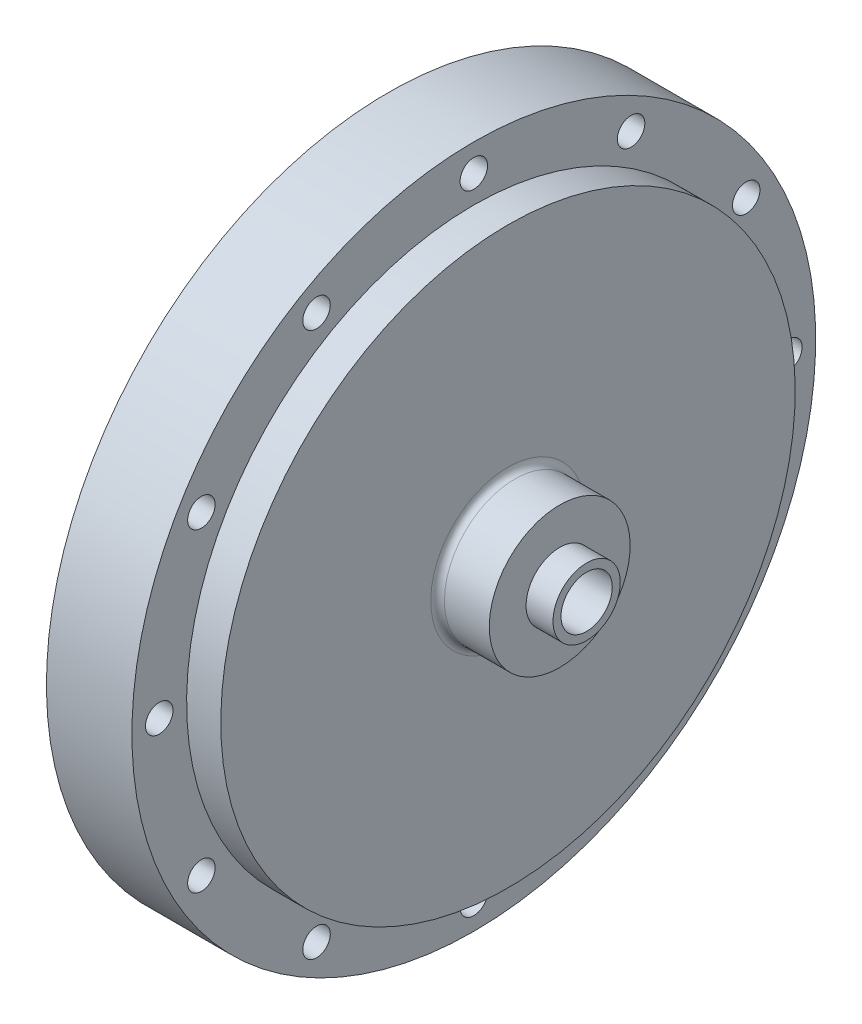
from build123d import *

# Parameters (mm, degrees)
SKETCH3_R                 = 4.7625
OXIDIZER_INLET_HOLE_DEPTH = 37.83
FLANGE_HOLES_D            = 5.1054
FLANGE_HOLES_DEPTH        = 22.225
DOWEL_HOLES_D             = 4.7625
DOWEL_HOLES_DEPTH         = 6.35
DOWEL_HOLES_TIP           = 1.430799349
SKETCH12_R                = 28.575
CUT_EXTRUDE2_DEPTH        = 9.525
SKETCH16_R                = 28.575
SKETCH17_R                = 4.7625
CIRPATTERN1_COUNT         = 8
FILLET1_R                 = 1.27
SKETCH25_OUTSIDE_W        = 165.668
SKETCH25_OUTSIDE_H        = 165.668
SKETCH25_OUTSIDE_R        = 53.34
CUT_EXTRUDE3_DEPTH        = 6.35


with BuildPart() as part:
    # Sketch2 → Main Structure (revolve)
    with BuildSketch(Plane.XY):
        Polygon((41.355, 13.081), (41.355, 6.2484), (46.355, 6.2484), (46.355, 0), (9.525, 0), (9.525, 63.5), (31.75, 63.5), (31.75, 13.081), align=None)
    revolve(axis=Axis((9.525, 0, 0), (1, 0, 0)))

    # Sketch3 → Oxidizer Inlet Hole (cut, through all)
    with BuildSketch(Plane(origin=(46.355, 0, 0), x_dir=(0, 0, -1), z_dir=(1, 0, 0))):
        Circle(SKETCH3_R)
    extrude(amount=-OXIDIZER_INLET_HOLE_DEPTH, mode=Mode.SUBTRACT)

    # Flange Holes
    with Locations(Plane(origin=(31.75, 0, 0), x_dir=(0, 0, 1), z_dir=(1, 0, 0))):
        with Locations((0, 58.42), (-29.21, 50.593204089), (-50.593204089, 29.21), (-58.42, 0), (-50.593204089, -29.21), (-29.21, -50.593204089), (0, -58.42), (29.21, -50.593204089), (50.593204089, -29.21), (58.42, 0), (50.593204089, 29.21), (29.21, 50.593204089)):
            Hole(FLANGE_HOLES_D / 2, depth=FLANGE_HOLES_DEPTH)

    # Dowel Holes
    with Locations(Plane.ZY.offset(-9.525)):
        with Locations((56.429386772, -15.120208615), (-56.429386772, 15.120208615)):
            Hole(DOWEL_HOLES_D / 2, depth=DOWEL_HOLES_DEPTH)
            with Locations((0, 0, -(DOWEL_HOLES_DEPTH + DOWEL_HOLES_TIP / 2))):  # 118° drill point
                Cone(0, DOWEL_HOLES_D / 2, DOWEL_HOLES_TIP, mode=Mode.SUBTRACT)

    # Sketch12 → Cut-Extrude2 (cut)
    with BuildSketch(Plane.ZY.offset(-9.525)):
        Circle(SKETCH12_R)
    extrude(amount=-CUT_EXTRUDE2_DEPTH, mode=Mode.SUBTRACT)

    # Sketch16 → Internal Flow Path Loft Cut section 0
    with BuildSketch(Plane.ZY.offset(-19.05)):
        Circle(SKETCH16_R)
    # Sketch17 → Internal Flow Path Loft Cut section 1
    with BuildSketch(Plane.ZY.offset(-30.48)):
        Circle(SKETCH17_R)
    loft(mode=Mode.SUBTRACT)

    # Sketch20 → #4-40 Tapped Hole1 (revolve, cut)
    with BuildSketch(Plane(origin=(9.525, 0, 33.3375), x_dir=(0, 0, 1), z_dir=(0, 1, 0))):
        Polygon((0, 0), (0, 13.887152758), (1.1303, 13.208), (1.1303, 0), align=None)
    f_4_40_tapped_hole1 = revolve(axis=Axis((3.175, 0, 33.3375), (1, 0, 0)), mode=Mode.SUBTRACT)

    # CirPattern1: #4-40 Tapped Hole1 ×8 about axis
    cirpattern1_axis = Axis((0, 0, 0), (1, 0, 0))
    for i in range(1, CIRPATTERN1_COUNT):
        add(f_4_40_tapped_hole1.rotate(cirpattern1_axis, i * 360 / CIRPATTERN1_COUNT), mode=Mode.SUBTRACT)

    # Fillet1
    fillet1_edges = [part.edges().sort_by_distance(p)[0] for p in [
        (31.75, -13.081, 0),
    ]]
    fillet(fillet1_edges, radius=FILLET1_R)

    # Sketch25 outside → Cut-Extrude3 (cut)
    with BuildSketch(Plane(origin=(31.75, 0, 0), x_dir=(0, 0, -1), z_dir=(1, 0, 0))):
        Rectangle(SKETCH25_OUTSIDE_W, SKETCH25_OUTSIDE_H)
        Circle(SKETCH25_OUTSIDE_R, mode=Mode.SUBTRACT)
    extrude(amount=-CUT_EXTRUDE3_DEPTH, mode=Mode.SUBTRACT)


solid = part.part
